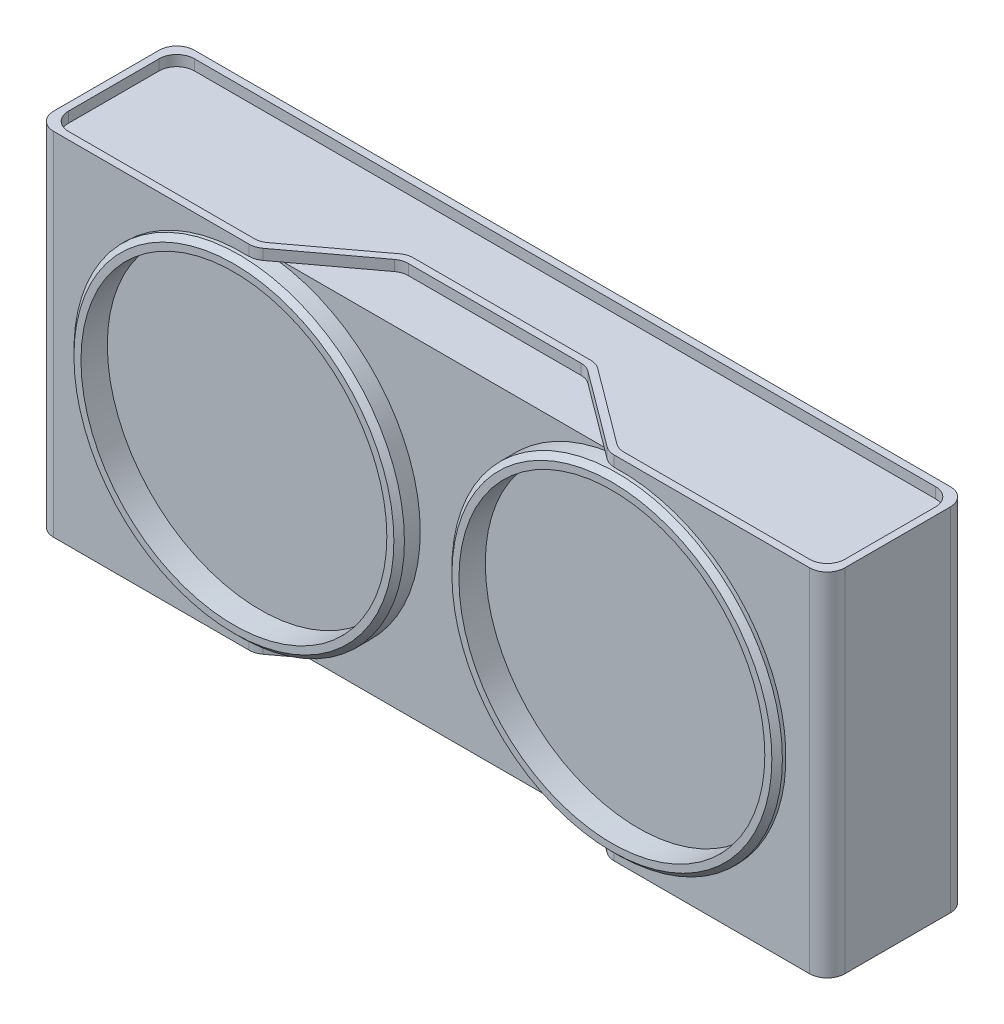
from build123d import *

# Parameters (mm, degrees)
SKETCH1_W              = 45
SKETCH1_H              = 20
BOSS_EXTRUDE1_DEPTH    = 8
FILLET1_R              = 1
SKETCH3_R              = 9.4
SKETCH3_R_2            = 8.7
BOSS_EXTRUDE2_DEPTH    = 0.5
CUT_EXTRUDE1_DEPTH     = 0.6
FILLET2_R              = 1
LPATTERN3_COUNT        = 2
LPATTERN3_PITCH        = 19.4
FILLET2_OF_LPATTERN3_R = 1
SKETCH6_W              = 20.76252332
SKETCH6_H              = 18.8
CUT_EXTRUDE3_DEPTH     = 0.7
SKETCH7_R              = 9.4
SKETCH7_R_2            = 8.7
BOSS_EXTRUDE4_DEPTH    = 1.3
SKETCH8_R              = 9.4
SKETCH8_R_2            = 8.7
BOSS_EXTRUDE5_DEPTH    = 1.3
CHAMFER1_SIZE          = 0.3
SKETCH12_R             = 8.7
CUT_EXTRUDE4_DEPTH     = 1
SKETCH13_R             = 8.7
CUT_EXTRUDE5_DEPTH     = 1
SKETCH19_W             = 1.5
SKETCH19_H             = 13
SKETCH19_W_2           = 2
SKETCH19_H_2           = 1
CUT_EXTRUDE6_DEPTH     = 40


with BuildPart() as part:
    # Sketch1 → Boss-Extrude1 (new body)
    with BuildSketch(Plane.XY):
        with Locations((22.5, 10)):
            Rectangle(SKETCH1_W, SKETCH1_H)
    extrude(amount=BOSS_EXTRUDE1_DEPTH)

    # Fillet1
    fillet1_edges = [part.edges().sort_by_distance(p)[0] for p in [
        (45, 10, 8),
        (0, 10, 8),
        (45, 10, 0),
        (0, 10, 0),
    ]]
    fillet(fillet1_edges, radius=FILLET1_R)

    # Sketch3 → Boss-Extrude2 (add)
    with BuildSketch(Plane.XY.offset(8)):
        with Locations((11.75, 10)):
            Circle(SKETCH3_R)
        with Locations((11.75, 10)):
            Circle(SKETCH3_R_2, mode=Mode.SUBTRACT)
        with Locations((33.25, 10)):
            Circle(SKETCH3_R)
        with Locations((33.25, 10)):
            Circle(SKETCH3_R_2, mode=Mode.SUBTRACT)
    extrude(amount=BOSS_EXTRUDE2_DEPTH)

    # Sketch4 → Cut-Extrude1 (cut)
    with BuildSketch(Plane.XZ):
        Polygon((27.739375, 4.42), (32.55, 8), (12.45, 8), (17.260625, 4.42), align=None)
        Polygon((44.58, 7.58), (32.685625, 7.58), (27.875, 4), (27.175, 4), (17.825, 4), (17.125, 4), (12.314375, 7.58), (0.42, 7.58), (0.42, 0.42), (44.58, 0.42), align=None)
    cut_extrude1 = extrude(amount=-CUT_EXTRUDE1_DEPTH, mode=Mode.SUBTRACT)

    # Fillet2
    fillet2_edges = [part.edges().sort_by_distance(p)[0] for p in [
        (0.42, 0.3, 7.58),
        (12.314375, 0.3, 7.58),
        (17.125, 0.3, 4),
        (27.875, 0.3, 4),
        (32.685625, 0.3, 7.58),
        (44.58, 0.3, 7.58),
        (44.58, 0.3, 0.42),
        (0.42, 0.3, 0.42),
        (17.260625, 0.3, 4.42),
        (12.45, 0.3, 8),
        (32.55, 0.3, 8),
        (27.739375, 0.3, 4.42),
    ]]
    fillet(fillet2_edges, radius=FILLET2_R)

    # LPattern3: Cut-Extrude1 ×2
    with Locations(*[(0, i * LPATTERN3_PITCH, 0) for i in range(1, LPATTERN3_COUNT)]):
        add(cut_extrude1, mode=Mode.SUBTRACT)

    # Fillet2 of LPattern3
    fillet2_of_lpattern3_edges = [part.edges().sort_by_distance(p)[0] for p in [
        (0.42, 19.7, 7.58),
        (12.314375, 19.7, 7.58),
        (17.125, 19.7, 4),
        (27.875, 19.7, 4),
        (32.685625, 19.7, 7.58),
        (44.58, 19.7, 7.58),
        (44.58, 19.7, 0.42),
        (0.42, 19.7, 0.42),
        (17.260625, 19.7, 4.42),
        (12.45, 19.7, 8),
        (32.55, 19.7, 8),
        (27.739375, 19.7, 4.42),
    ]]
    fillet(fillet2_of_lpattern3_edges, radius=FILLET2_OF_LPATTERN3_R)

    # Sketch6 → Cut-Extrude3 (cut)
    with BuildSketch(Plane.XY.offset(8)):
        with Locations((22.5, 10)):
            Rectangle(SKETCH6_W, SKETCH6_H)
    extrude(amount=-CUT_EXTRUDE3_DEPTH, mode=Mode.SUBTRACT)

    # Sketch7 → Boss-Extrude4 (add)
    with BuildSketch(Plane.XY.offset(8.5)):
        with Locations((11.75, 10)):
            Circle(SKETCH7_R)
        with Locations((11.75, 10)):
            Circle(SKETCH7_R_2, mode=Mode.SUBTRACT)
    extrude(amount=-BOSS_EXTRUDE4_DEPTH)

    # Sketch8 → Boss-Extrude5 (add)
    with BuildSketch(Plane.XY.offset(8.5)):
        with Locations((33.25, 10)):
            Circle(SKETCH8_R)
        with Locations((33.25, 10)):
            Circle(SKETCH8_R_2, mode=Mode.SUBTRACT)
    extrude(amount=-BOSS_EXTRUDE5_DEPTH)

    # Chamfer1
    chamfer1_edges = [part.edges().sort_by_distance(p)[0] for p in [
        (2.35, 10, 8.5),
        (23.85, 10, 8.5),
    ]]
    chamfer(chamfer1_edges, length=CHAMFER1_SIZE)

    # Sketch12 → Cut-Extrude4 (cut)
    with BuildSketch(Plane.XY.offset(8)):
        with Locations((33.25, 10)):
            Circle(SKETCH12_R)
    extrude(amount=-CUT_EXTRUDE4_DEPTH, mode=Mode.SUBTRACT)

    # Sketch13 → Cut-Extrude5 (cut)
    with BuildSketch(Plane.XY.offset(8)):
        with Locations((11.75, 10)):
            Circle(SKETCH13_R)
    extrude(amount=-CUT_EXTRUDE5_DEPTH, mode=Mode.SUBTRACT)

    # Sketch19 → Cut-Extrude6 (cut)
    with BuildSketch(Plane.ZY):
        with Locations((5.75, 10)):
            Rectangle(SKETCH19_W, SKETCH19_H)
        with Locations((4, 10)):
            Rectangle(SKETCH19_W_2, SKETCH19_H)
        with Locations((4, 17)):
            Rectangle(SKETCH19_W_2, SKETCH19_H_2)
        with Locations((4, 3)):
            Rectangle(SKETCH19_W_2, SKETCH19_H_2)
        with Locations((2.25, 10)):
            Rectangle(SKETCH19_W, SKETCH19_H)
    extrude(amount=-CUT_EXTRUDE6_DEPTH, mode=Mode.SUBTRACT)


solid = part.part
